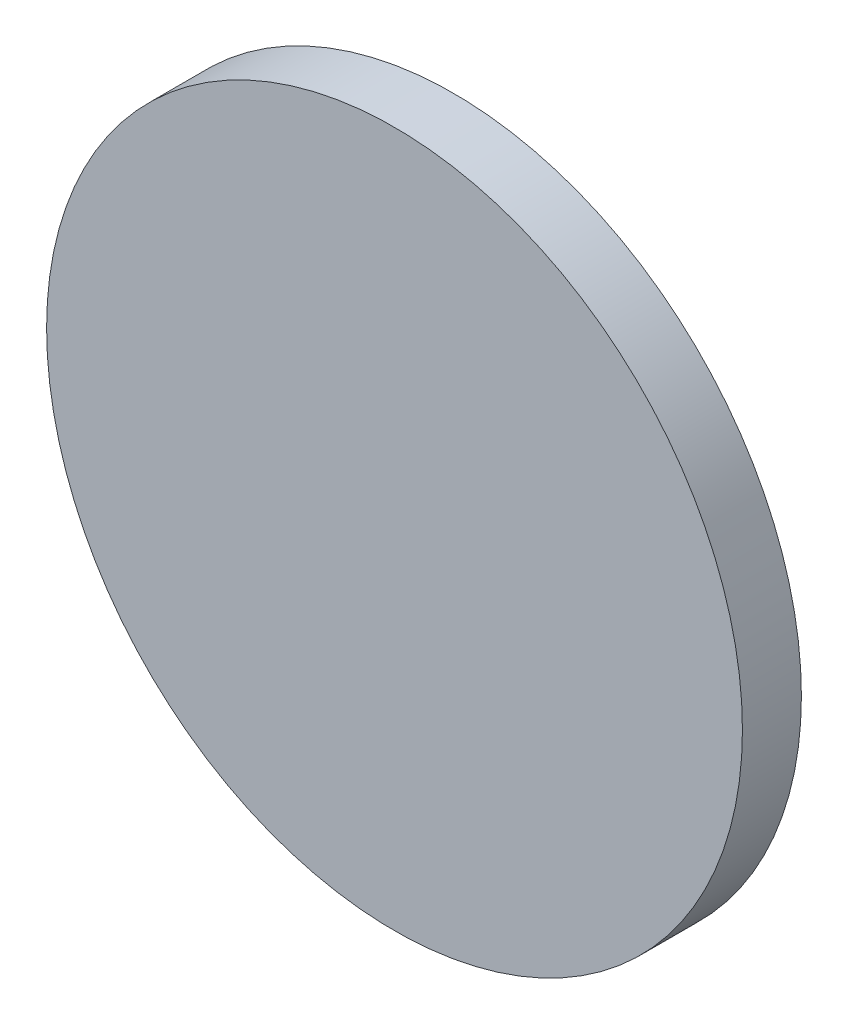
from build123d import *

# Parameters (mm, degrees)
SKETCH2_R           = 29.5
BOSS_EXTRUDE1_DEPTH = 60
CUT_REVOLVE1_ANGLE  = 180
CUT_EXTRUDE1_REACH  = 12
SKETCH5_W           = 91.768804765
SKETCH5_H           = 88.75511019
SKETCH6_R           = 10.1
CUT_EXTRUDE2_DEPTH  = 2
SKETCH7_W           = 64.282541495
SKETCH7_H           = 65.701050647
CUT_EXTRUDE3_DEPTH  = 45


with BuildPart() as part:
    # Sketch2 → Boss-Extrude1 (new body)
    with BuildSketch(Plane.XY):
        Circle(SKETCH2_R)
    extrude(amount=BOSS_EXTRUDE1_DEPTH)

    # Sketch4 → Cut-Revolve1 (revolve, cut)
    with BuildSketch(Plane.XY.offset(55)):
        with BuildLine():
            Line((-16.25, 0), (16.25, 0))
            ThreePointArc((16.25, 0), (0, 16.25), (-16.25, 0))
        make_face()
    revolve(axis=Axis((-16.25, 0, 55), (-1, 0, 0)), revolution_arc=CUT_REVOLVE1_ANGLE, mode=Mode.SUBTRACT)

    # Sketch5 → Cut-Extrude1 (cut, up to next)
    with BuildSketch(Plane.XY.offset(50), mode=Mode.PRIVATE) as cut_extrude1_sk1:
        with Locations((1.214417884, -2.093280901)):
            Rectangle(SKETCH5_W, SKETCH5_H)
    cut_extrude1_tool1 = extrude(cut_extrude1_sk1.sketch, amount=CUT_EXTRUDE1_REACH, mode=Mode.PRIVATE) & part.part
    add(cut_extrude1_tool1.solids().sort_by_distance((1.214418, -2.093281, 50))[0], mode=Mode.SUBTRACT)

    # Sketch6 → Cut-Extrude2 (cut)
    with BuildSketch(Plane(origin=(0, 0, 0), x_dir=(-1, 0, 0), z_dir=(0, 0, -1))):
        Circle(SKETCH6_R)
    extrude(amount=-CUT_EXTRUDE2_DEPTH, mode=Mode.SUBTRACT)

    # Sketch7 → Cut-Extrude3 (cut)
    with BuildSketch(Plane.XY.offset(50)):
        with Locations((0.667192443, 0.630931985)):
            Rectangle(SKETCH7_W, SKETCH7_H)
    extrude(amount=-CUT_EXTRUDE3_DEPTH, mode=Mode.SUBTRACT)


solid = part.part
